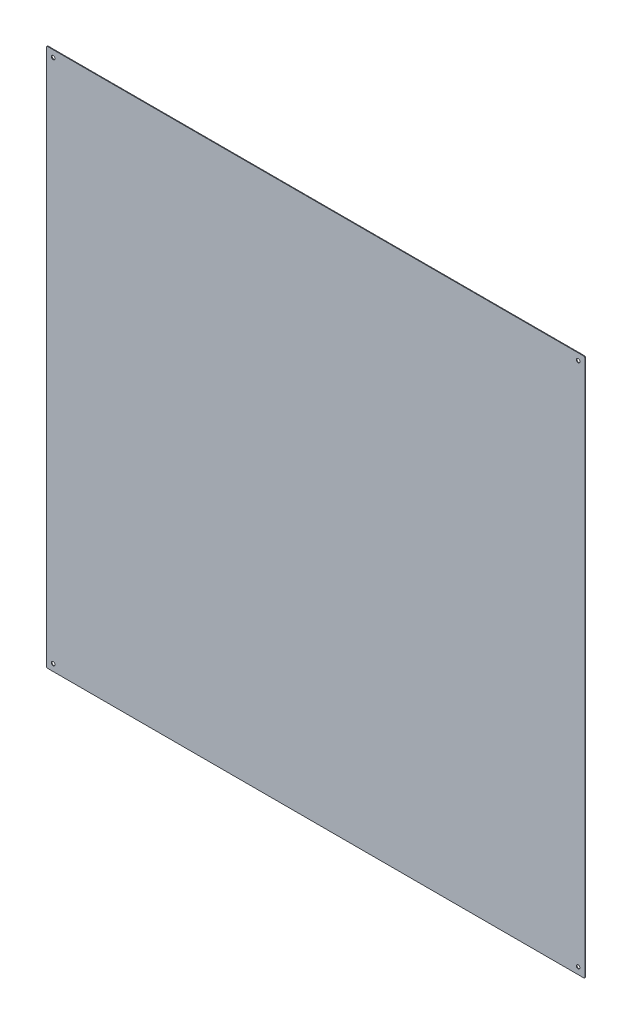
from build123d import *

# Parameters (mm, degrees)
SKETCH1_W           = 1205
SKETCH1_H           = 1205
BOSS_EXTRUDE1_DEPTH = 1.5
FILLET1_R           = 3
SKETCH2_R           = 4
CUT_EXTRUDE1_DEPTH  = 2.5


with BuildPart() as part:
    # Sketch1 → Boss-Extrude1 (new body)
    with BuildSketch(Plane.XY.offset(6)):
        Rectangle(SKETCH1_W, SKETCH1_H)
    extrude(amount=BOSS_EXTRUDE1_DEPTH)

    # Fillet1
    fillet1_edges = [part.edges().sort_by_distance(p)[0] for p in [
        (602.5, -602.5, 6.75),
        (-602.5, -602.5, 6.75),
        (-602.5, 602.5, 6.75),
        (602.5, 602.5, 6.75),
    ]]
    fillet(fillet1_edges, radius=FILLET1_R)

    # Sketch2 → Cut-Extrude1 (cut, through all)
    with BuildSketch(Plane(origin=(0, 0, 6), x_dir=(-1, 0, 0), z_dir=(0, 0, -1))):
        with Locations((587.32233047, -587.32233047)):
            Circle(SKETCH2_R)
        with Locations((-587.32233047, -587.32233047)):
            Circle(SKETCH2_R)
        with Locations((-587.32233047, 587.32233047)):
            Circle(SKETCH2_R)
        with Locations((587.32233047, 587.32233047)):
            Circle(SKETCH2_R)
    extrude(amount=-CUT_EXTRUDE1_DEPTH, mode=Mode.SUBTRACT)


solid = part.part
